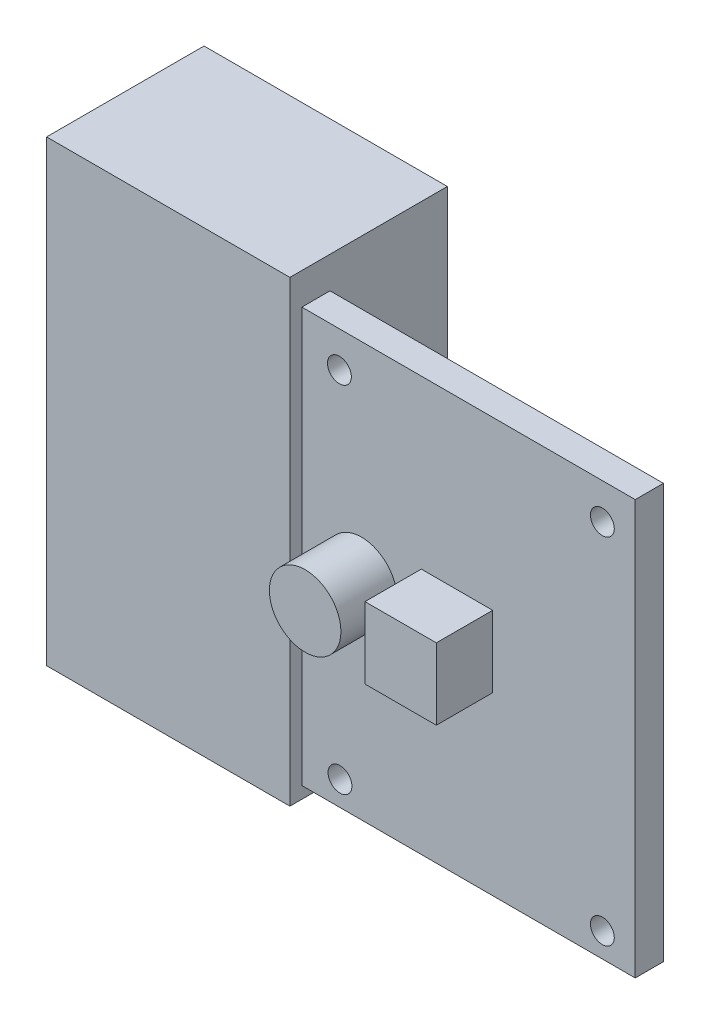
from build123d import *

# Parameters (mm, degrees)
SKETCH1_W                = 35.5
SKETCH1_H                = 44.12
SKETCH1_R                = 3.81
SKETCH1_R_2              = 1.27
SKETCH1_W_2              = 7.6
SKETCH1_H_2              = 7.6
BOSS_EXTRUDE1_DEPTH      = 3
SKETCH2_W                = 25.908
SKETCH2_H                = 48.768
BOSS_EXTRUDE4_DEPTH      = 0.00254
BOSS_EXTRUDE4_DEPTH_BACK = 16.764
SKETCH3_R                = 3.81
BOSS_EXTRUDE5_DEPTH      = 6
SKETCH3_W                = 7.6
SKETCH3_H                = 7.6
BOSS_EXTRUDE5_2_DEPTH    = 6


with BuildPart() as part:
    # Sketch1 → Boss-Extrude1 (new body)
    with BuildSketch(Plane.XY):
        with Locations((-17.75, 22.06)):
            Rectangle(SKETCH1_W, SKETCH1_H)
        with Locations((-29.15, 22.276)):
            Circle(SKETCH1_R, mode=Mode.SUBTRACT)
        with Locations((-31.44, 2.6)):
            Circle(SKETCH1_R_2, mode=Mode.SUBTRACT)
        with Locations((-3.5, 2.6)):
            Circle(SKETCH1_R_2, mode=Mode.SUBTRACT)
        with Locations((-3.5, 40.32)):
            Circle(SKETCH1_R_2, mode=Mode.SUBTRACT)
        with Locations((-31.5, 40.32)):
            Circle(SKETCH1_R_2, mode=Mode.SUBTRACT)
        with Locations((-18.98, 22.52)):
            Rectangle(SKETCH1_W_2, SKETCH1_H_2, mode=Mode.SUBTRACT)
    extrude(amount=BOSS_EXTRUDE1_DEPTH)


with BuildPart() as body_2:
    # Sketch2 → Boss-Extrude4 (new body, two sides)
    with BuildSketch(Plane.XY.offset(3)) as boss_extrude4_sk:
        with Locations((-49.724, 21.844)):
            Rectangle(SKETCH2_W, SKETCH2_H)
    extrude(amount=BOSS_EXTRUDE4_DEPTH)
    extrude(boss_extrude4_sk.sketch, amount=-BOSS_EXTRUDE4_DEPTH_BACK)


with BuildPart() as body_3:
    # Sketch3 → Boss-Extrude5 (new body)
    with BuildSketch(Plane.XY.offset(3)):
        with Locations((-29.15, 22.276)):
            Circle(SKETCH3_R)
    extrude(amount=BOSS_EXTRUDE5_DEPTH)


with BuildPart() as body_4:
    # Sketch3 → Boss-Extrude5 2 (new body)
    with BuildSketch(Plane.XY.offset(3)):
        with Locations((-18.98, 22.52)):
            Rectangle(SKETCH3_W, SKETCH3_H)
    extrude(amount=BOSS_EXTRUDE5_2_DEPTH)


solid = Compound([part.part, body_2.part, body_3.part, body_4.part])
